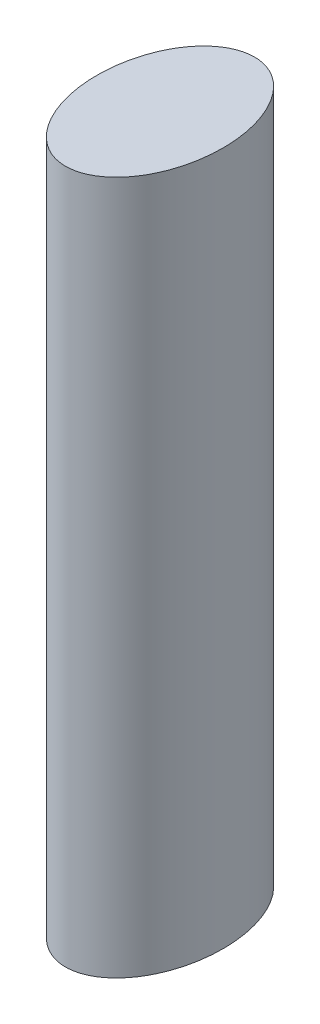
from build123d import *

# Parameters (mm, degrees)
SKETCH2_RX          = 15
SKETCH2_RY          = 10
BOSS_EXTRUDE1_DEPTH = 110


with BuildPart() as part:
    # Sketch2 → Boss-Extrude1 (new body)
    with BuildSketch(Plane(origin=(0, 0, 0), x_dir=(1, 0, 0), z_dir=(0, 1, 0))):
        with Locations(Location((0, 0), (0, 0, 90))):
            Ellipse(SKETCH2_RX, SKETCH2_RY)
    extrude(amount=BOSS_EXTRUDE1_DEPTH)


solid = part.part
